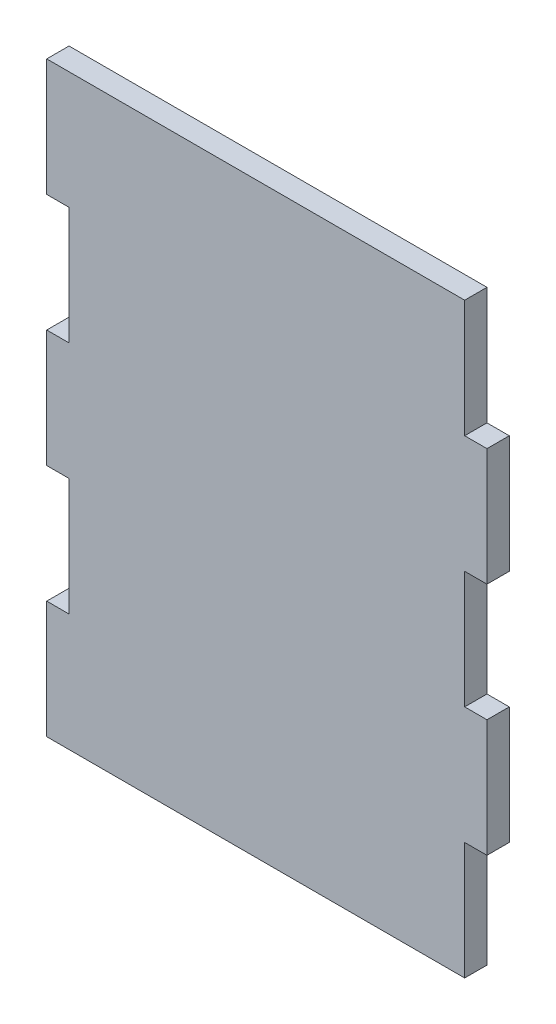
from build123d import *

# Parameters (mm, degrees)
BOSS_EXTRUDE1_DEPTH = 4.826


with BuildPart() as part:
    # Sketch1 → Boss-Extrude1 (new body)
    with BuildSketch(Plane.XY):
        Polygon((-47.625, -38.1), (-47.625, -63.5), (42.799, -63.5), (42.799, -38.1), (47.625, -38.1), (47.625, -12.7), (42.799, -12.7), (42.799, 12.7), (47.625, 12.7), (47.625, 38.1), (42.799, 38.1), (42.799, 63.5), (-47.625, 63.5), (-47.625, 38.1), (-42.799, 38.1), (-42.799, 12.7), (-47.625, 12.7), (-47.625, -12.7), (-42.799, -12.7), (-42.799, -38.1), align=None)
    extrude(amount=BOSS_EXTRUDE1_DEPTH)


solid = part.part
